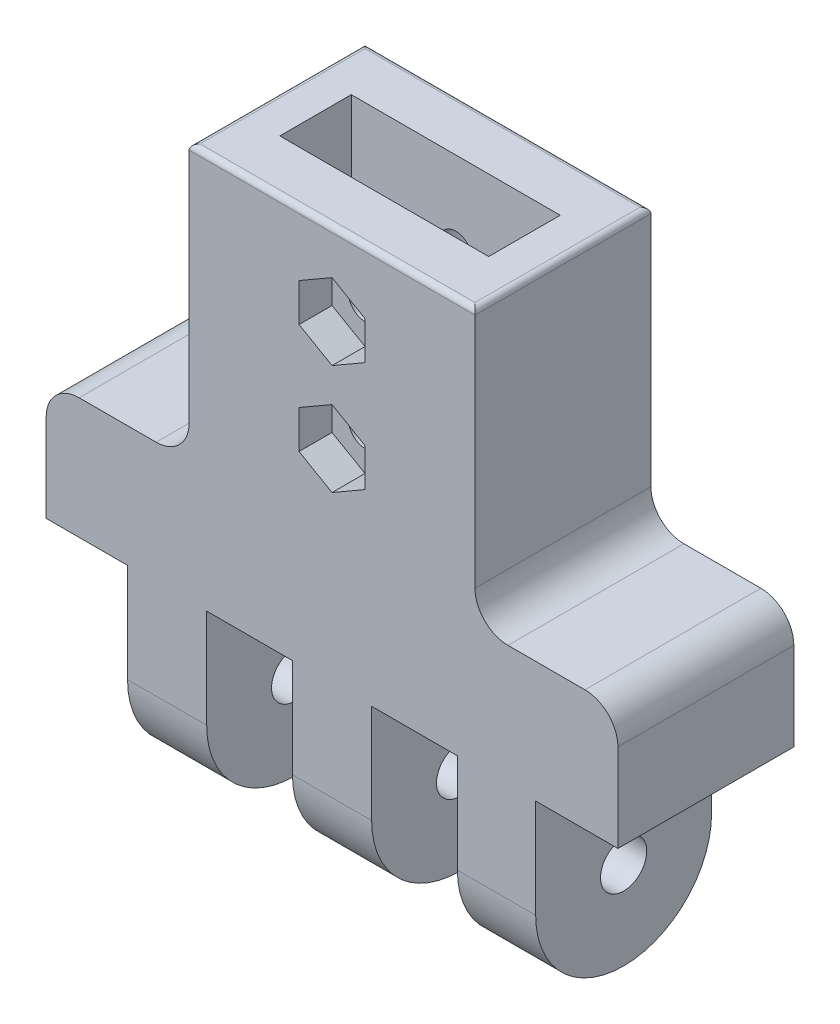
from build123d import *

# Parameters (mm, degrees)
SKETCH2_R           = 2.1
BOSS_EXTRUDE1_DEPTH = 26
SKETCH3_W           = 7.4
SKETCH3_H           = 18
SKETCH3_W_2         = 7.8
SKETCH3_W_3         = 7.481047655
CUT_EXTRUDE1_DEPTH  = 17
SKETCH4_W           = 26
SKETCH4_H           = 16
BOSS_EXTRUDE2_DEPTH = 25
SKETCH5_W           = 19
SKETCH5_H           = 6.5
CUT_EXTRUDE2_DEPTH  = 25
FILLET2_R           = 3
SKETCH6_R           = 1.5
CUT_EXTRUDE3_DEPTH  = 12.5
FILLET3_R           = 0.5
FILLET4_R           = 3
CUT_EXTRUDE4_DEPTH  = 3


with BuildPart() as part:
    # Sketch2 → Boss-Extrude1 (new body, symmetric)
    with BuildSketch(Plane(origin=(0, 0, 0), x_dir=(0, 0, -1), z_dir=(1, 0, 0))):
        with BuildLine():
            Line((-8, 0), (-8, 20))
            Line((-8, 20), (8, 20))
            Line((8, 20), (8, 0))
            ThreePointArc((8, 0), (0, -8), (-8, 0))
        make_face()
        Circle(SKETCH2_R, mode=Mode.SUBTRACT)
    extrude(amount=BOSS_EXTRUDE1_DEPTH, both=True)

    # Sketch3 → Cut-Extrude1 (cut, through all)
    with BuildSketch(Plane.XY.offset(8)):
        with Locations((-22.3, 0)):
            Rectangle(SKETCH3_W, SKETCH3_H)
        with Locations((-7.5, 0)):
            Rectangle(SKETCH3_W_2, SKETCH3_H)
        with Locations((7.5, 0)):
            Rectangle(SKETCH3_W_2, SKETCH3_H)
        with Locations((22.259476173, 0)):
            Rectangle(SKETCH3_W_3, SKETCH3_H)
    extrude(amount=-CUT_EXTRUDE1_DEPTH, mode=Mode.SUBTRACT)

    # Sketch4 → Boss-Extrude2 (add)
    with BuildSketch(Plane(origin=(0, 20, 0), x_dir=(1, 0, 0), z_dir=(0, 1, 0))):
        Rectangle(SKETCH4_W, SKETCH4_H)
    extrude(amount=BOSS_EXTRUDE2_DEPTH)

    # Sketch5 → Cut-Extrude2 (cut)
    with BuildSketch(Plane(origin=(0, 45, 0), x_dir=(1, 0, 0), z_dir=(0, 1, 0))):
        Rectangle(SKETCH5_W, SKETCH5_H)
    extrude(amount=-CUT_EXTRUDE2_DEPTH, mode=Mode.SUBTRACT)

    # Fillet2
    fillet2_edges = [part.edges().sort_by_distance(p)[0] for p in [
        (26, 20, 0),
        (-26, 20, 0),
    ]]
    fillet(fillet2_edges, radius=FILLET2_R)

    # Sketch6 → Cut-Extrude3 (cut, symmetric)
    with BuildSketch(Plane.XY):
        with Locations((0, 37.5)):
            Circle(SKETCH6_R)
        with Locations((0, 27.5)):
            Circle(SKETCH6_R)
    extrude(amount=CUT_EXTRUDE3_DEPTH, both=True, mode=Mode.SUBTRACT)

    # Fillet3
    fillet3_edges = [part.edges().sort_by_distance(p)[0] for p in [
        (-13, 45, 0),
        (0, 45, 8),
        (13, 45, 0),
        (0, 45, -8),
    ]]
    fillet(fillet3_edges, radius=FILLET3_R)

    # Fillet4
    fillet4_edges = [part.edges().sort_by_distance(p)[0] for p in [
        (-13, 20, 0),
        (13, 20, 0),
    ]]
    fillet(fillet4_edges, radius=FILLET4_R)

    # Sketch7 → Cut-Extrude4 (cut)
    with BuildSketch(Plane.XY.offset(8)):
        Polygon((3, 35.767949192), (3, 39.232050808), (0, 40.964101615), (-3, 39.232050808), (-3, 35.767949192), (0, 34.035898385), align=None)
        Polygon((3, 25.767949192), (3, 29.232050808), (0, 30.964101615), (-3, 29.232050808), (-3, 25.767949192), (0, 24.035898385), align=None)
    extrude(amount=-CUT_EXTRUDE4_DEPTH, mode=Mode.SUBTRACT)


solid = part.part
